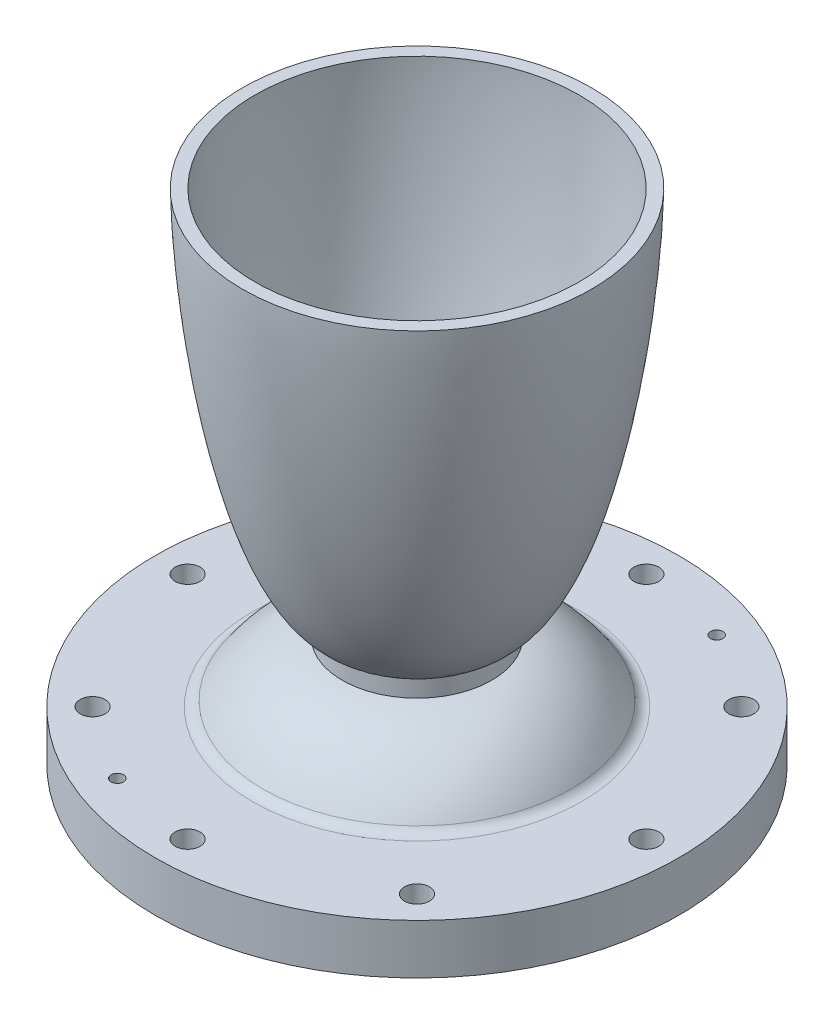
from build123d import *

# Parameters (mm, degrees)
CONVERGING_FILLET_R   = 3.175
BOLT_HOLES_D          = 6.35
BOLT_HOLES_DEPTH      = 12.7
BOLT_HOLES_TIP        = 1.907732465
PIN_HOLES_D           = 3.175
PIN_HOLES_DEPTH       = 100
PIN_HOLES_CBORE_D     = 6.35
PIN_HOLES_CBORE_DEPTH = 6.35


with BuildPart() as part:
    # Sketch1 → Main Revolve (revolve)
    with BuildSketch(Plane.XY):
        with BuildLine():
            Line((-9.517884855, 29.85426414), (-9.517884855, 31.004317662))
            ThreePointArc((-9.517884855, 31.004317662), (-10.387063469, 33.747209355), (-12.677340956, 35.488919819))
            add(Edge.make_bspline(
                [(-41.275, 127), (-41.268873036, 126.161357833), (-41.222997706, 124.484568363), (-41.073369126, 121.078528782), (-40.722786085, 115.949040077), (-40.170467422, 109.939618965), (-39.360849464, 103.059106185), (-38.382227863, 96.200616774), (-37.230570221, 89.368983139), (-35.895631241, 82.570619969), (-34.35912374, 75.814773558), (-32.593807355, 69.114550244), (-30.558516971, 62.490757957), (-28.191269221, 55.976383127), (-25.683140783, 50.29180013), (-23.125834222, 45.592543641), (-20.711209845, 42.055498174), (-18.720317843, 39.685916503), (-17.052831983, 38.103539579), (-15.746862259, 37.100217478), (-14.77072941, 36.476537732), (-14.077416444, 36.090491664), (-13.464775463, 35.797858298), (-13.037564762, 35.6215562), (-12.773284859, 35.523215456), (-12.677340956, 35.488919819)],
                knots=[0, 0, 0, 0, 0, 0.030811657, 0.061623313, 0.125250249, 0.188877076, 0.252503727, 0.31613061, 0.379757458, 0.443384315, 0.507011165, 0.570638032, 0.634264894, 0.697891611, 0.761518516, 0.798698062, 0.830511144, 0.855003573, 0.875012249, 0.882965592, 0.890918935, 0.897534321, 0.904149707, 0.907892787, 0.907892787, 0.907892787, 0.907892787, 0.907892787], degree=4))
            Line((-41.275, 127), (-44.449999999, 127))
            add(Edge.make_bspline(
                [(-44.449999999, 127), (-44.444048095, 126.089867786), (-44.399723494, 124.270031311), (-44.256170835, 120.604636062), (-43.921206973, 115.098603125), (-43.395046361, 108.666141993), (-42.624644612, 101.314791698), (-41.691159468, 93.9823601), (-40.588904101, 86.673339257), (-39.305520483, 79.393738689), (-37.819617038, 72.152599105), (-36.098890328, 64.963007024), (-34.092981802, 57.847082032), (-31.766198141, 50.972017381), (-29.315037347, 45.128649076), (-26.838138987, 40.469327818), (-24.570330265, 37.178251455), (-22.783120415, 35.132973657), (-21.307300799, 33.836487802), (-20.194653885, 33.074782772), (-19.515295281, 32.700466394), (-19.20577242, 32.548791321), (-19.05, 32.47725184)],
                knots=[0, 0, 0, 0, 0, 0.033160808, 0.066321616, 0.133644696, 0.20096779, 0.268290787, 0.335613842, 0.40293693, 0.470260007, 0.537583094, 0.604906139, 0.672229114, 0.739552316, 0.801869766, 0.835531618, 0.86410438, 0.88489762, 0.900577549, 0.906888404, 0.913134212, 0.913134212, 0.913134212, 0.913134212, 0.913134212], degree=4))
            Line((-19.05, 32.47725184), (-19.049955181, 28.041753321))
            add(Edge.make_bspline(
                [(-40.132928845, 12.7), (-40.083978858, 12.784156262), (-39.983265103, 12.955401456), (-39.759808639, 13.330999271), (-39.546364559, 13.67507087), (-39.221651837, 14.190368882), (-38.914624104, 14.656083798), (-38.583549151, 15.143878505), (-38.186353269, 15.705830102), (-37.77509929, 16.268618988), (-37.2843995, 16.909714234), (-36.702796259, 17.630765959), (-36.103434504, 18.334481647), (-35.484819509, 19.022919017), (-34.848061727, 19.693649754), (-34.192734181, 20.346852672), (-33.519373114, 20.981085312), (-32.827952052, 21.595818623), (-31.962967273, 22.320542927), (-31.070351962, 23.011417112), (-30.150953105, 23.666133634), (-29.205505922, 24.282436301), (-28.414577383, 24.76223971), (-27.607968747, 25.215620128), (-26.786861464, 25.641439606), (-25.950949864, 26.038789389), (-25.102603979, 26.406415537), (-24.239975487, 26.743680196), (-23.368438554, 27.049008091), (-22.48141889, 27.322515066), (-21.704602088, 27.531618066), (-21.021032253, 27.69122915), (-20.468248248, 27.807088311), (-19.986741847, 27.896157232), (-19.629776323, 27.957756939), (-19.260320361, 28.012378489), (-19.106911701, 28.033992962), (-19.049955181, 28.041753321)],
                knots=[0.073786485, 0.073786485, 0.073786485, 0.073786485, 0.073786485, 0.088217084, 0.102647684, 0.117078284, 0.131508883, 0.160370079, 0.174800677, 0.189231275, 0.218092486, 0.246953697, 0.275814909, 0.304676121, 0.333537325, 0.362398529, 0.391259738, 0.420120946, 0.448982156, 0.477843365, 0.532083348, 0.560944559, 0.589805767, 0.618666976, 0.647528184, 0.676389393, 0.705250602, 0.734111807, 0.762973012, 0.79183422, 0.820695429, 0.849556636, 0.863987238, 0.87841784, 0.892848442, 0.907279044, 0.915799347, 0.915799347, 0.915799347, 0.915799347, 0.915799347], degree=4))
            Line((-40.132928845, 12.7), (-66.675, 12.7))
            Line((-66.675, 12.7), (-66.675, 0))
            Line((-66.675, 0), (-41.275, 0))
            add(Edge.make_bspline(
                [(-41.275, 0), (-41.27404827, 0.048633732), (-41.270265816, 0.145822286), (-41.249886429, 0.420698051), (-41.184454538, 0.952068232), (-41.045697232, 1.718226005), (-40.803050388, 2.710615824), (-40.471359514, 3.795919992), (-40.073863441, 4.892829094), (-39.58250679, 6.074812663), (-38.909330489, 7.49520986), (-38.013176032, 9.129802593), (-36.850990459, 10.946036297), (-35.454742127, 12.816921248), (-33.931439219, 14.585782904), (-32.290383905, 16.245919147), (-30.54007116, 17.790421623), (-28.688732636, 19.212251207), (-26.744575764, 20.504343604), (-24.716209135, 21.659734331), (-22.61250234, 22.671709773), (-20.443220111, 23.533972634), (-18.496293348, 24.152467466), (-16.799886455, 24.58239915), (-15.513443264, 24.843608525), (-14.65819574, 24.990901269), (-14.086451577, 25.07519752), (-13.804404299, 25.113562074), (-13.666257288, 25.131526207)],
                knots=[0, 0, 0, 0, 0, 0.004014849, 0.008029698, 0.022747096, 0.044177712, 0.068247366, 0.092316927, 0.116386463, 0.140456137, 0.173883837, 0.222022894, 0.270162138, 0.318301135, 0.366440287, 0.41457937, 0.462718533, 0.510857613, 0.558996755, 0.607135854, 0.655274938, 0.703414059, 0.751553162, 0.775622711, 0.799692261, 0.811727037, 0.823244082, 0.823244082, 0.823244082, 0.823244082, 0.823244082], degree=4))
            ThreePointArc((-13.666257288, 25.131526207), (-10.702243662, 26.711285957), (-9.517884855, 29.85426414))
        make_face()
    revolve(axis=Axis((0, 0, 0), (0, 1, 0)))

    # Converging Fillet
    converging_fillet_edges = [part.edges().sort_by_distance(p)[0] for p in [
        (40.132928845, 12.7, 0),
    ]]
    fillet(converging_fillet_edges, radius=CONVERGING_FILLET_R)

    # Bolt Holes
    with Locations(Plane(origin=(0, 12.7, 0), x_dir=(1, 0, 0), z_dir=(0, 1, 0))):
        with Locations((-58.42, 0), (-41.309178157, 41.309178157), (0, 58.42), (41.309178157, 41.309178157), (58.42, 0), (41.309178157, -41.309178157), (0, -58.42), (-41.309178157, -41.309178157)):
            Hole(BOLT_HOLES_D / 2, depth=BOLT_HOLES_DEPTH)
            with Locations((0, 0, -(BOLT_HOLES_DEPTH + BOLT_HOLES_TIP / 2))):  # 118° drill point
                Cone(0, BOLT_HOLES_D / 2, BOLT_HOLES_TIP, mode=Mode.SUBTRACT)

    # Pin Holes
    with Locations(Plane(origin=(0, 0, 0), x_dir=(-1, 0, 0), z_dir=(0, -1, 0))):
        with Locations((-22.356366119, 53.973042289), (22.356366119, -53.973042289)):
            CounterBoreHole(PIN_HOLES_D / 2, PIN_HOLES_CBORE_D / 2, PIN_HOLES_CBORE_DEPTH, depth=PIN_HOLES_DEPTH)


solid = part.part
